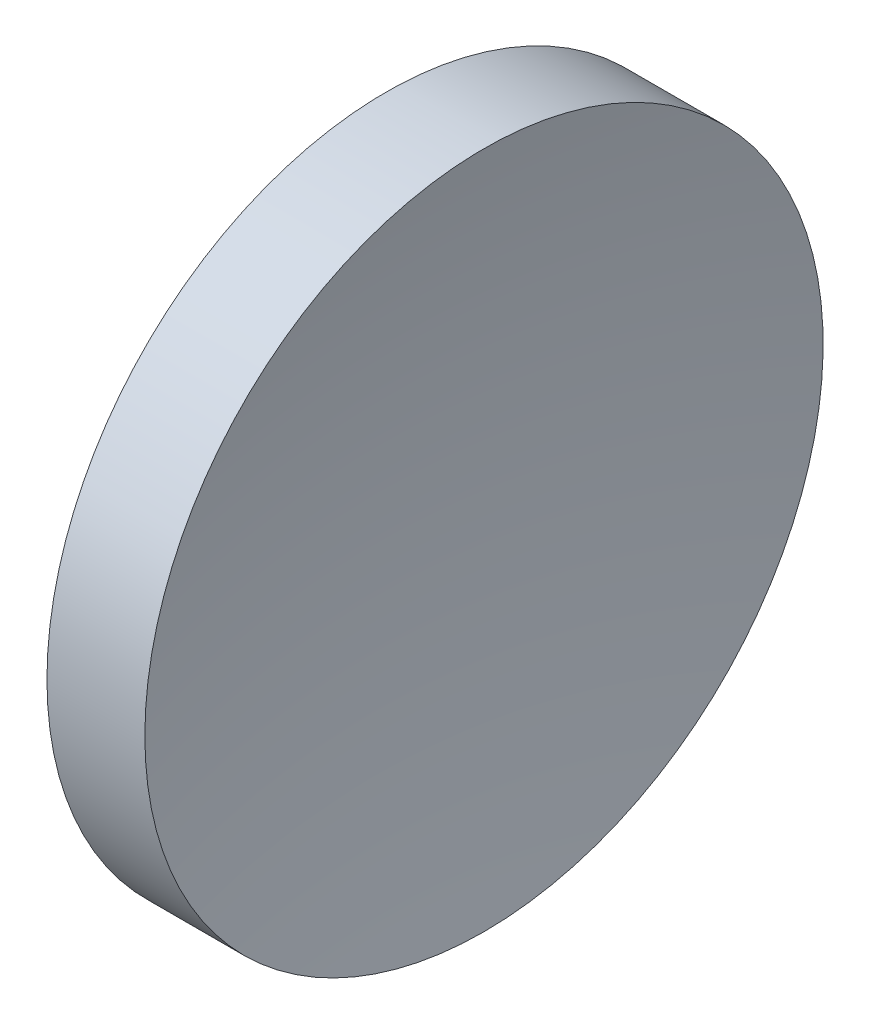
from build123d import *


with BuildPart() as part:
    # 草图1 → 旋转1 (revolve)
    with BuildSketch(Plane.XY, mode=Mode.PRIVATE) as revolve_1_sk:
        with BuildLine():
            Line((115.064634685, 82.221536258), (119.972292813, 82.221536258))
            ThreePointArc((119.972292813, 82.221536258), (118.730029632, 73.761849931), (118.314634685, 65.221536258))
            Line((118.314634685, 65.221536258), (115.064634685, 65.221536258))
            Line((115.064634685, 65.221536258), (115.064634685, 82.221536258))
        make_face()
    revolve(revolve_1_sk.sketch.rotate(Axis((103.233342166, 65.221536258, 0), (1, 0, 0)), 180), axis=Axis((103.233342166, 65.221536258, 0), (1, 0, 0)))  # turned: the seam where the file's is


solid = part.part
